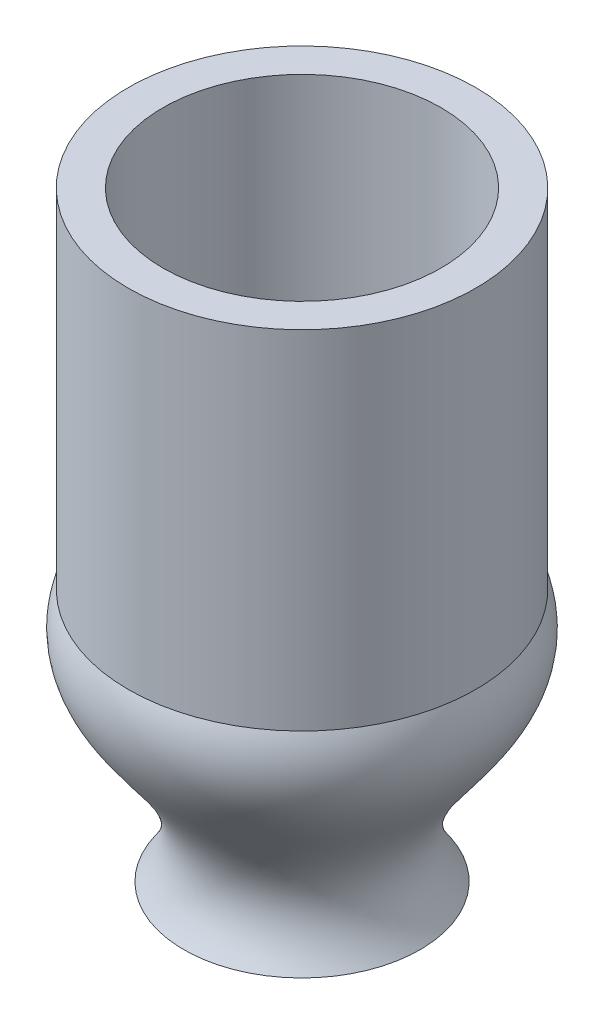
from build123d import *


with BuildPart() as part:
    # Эскиз9 → Повернуть1 (revolve)
    with BuildSketch(Plane.XY):
        with BuildLine():
            Line((32.763886378, 30.162149488), (32.763886378, 80.162149488))
            Line((32.763886378, 80.162149488), (27.763886378, 80.162149488))
            Line((27.763886378, 80.162149488), (27.763886378, 30.162149488))
            add(Edge.make_bspline(
                [(27.763886378, 30.162149488), (31.800599898, 15.448804189), (9.471740098, 8.360906449), (19.763886378, -6.260068598)],
                knots=[0, 0, 0, 0, 1, 1, 1, 1], degree=3))
            Line((19.763886378, -6.260068598), (24.763886378, -6.260068598))
            add(Edge.make_bspline(
                [(24.763886378, -6.260068598), (14.095716223, 8.032344283), (38.849973736, 14.960293312), (32.763886378, 30.162149488)],
                knots=[0, 0, 0, 0, 1, 1, 1, 1], degree=3))
        make_face()
    revolve(axis=Axis((7.763886378, -6.260068598, 0), (0, 1, 0)))


solid = part.part
